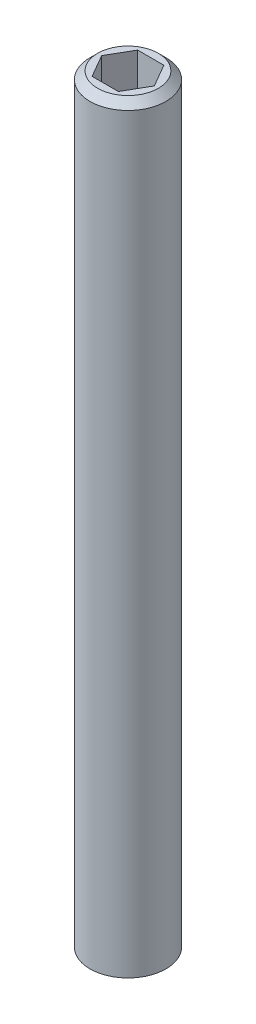
from build123d import *

# Parameters (mm, degrees)
SKETCH1_R           = 1.25
BOSS_EXTRUDE1_DEPTH = 25
CUT_EXTRUDE1_DEPTH  = 2
CHAMFER1_SIZE       = 0.25


with BuildPart() as part:
    # Sketch1 → Boss-Extrude1 (new body)
    with BuildSketch(Plane(origin=(0, 0, 0), x_dir=(1, 0, 0), z_dir=(0, 1, 0))):
        Circle(SKETCH1_R)
    extrude(amount=BOSS_EXTRUDE1_DEPTH)

    # Sketch2 → Cut-Extrude1 (cut)
    with BuildSketch(Plane(origin=(0, 25, 0), x_dir=(1, 0, 0), z_dir=(0, 1, 0))):
        Polygon((0.866025404, 0), (0.433012702, 0.75), (-0.433012702, 0.75), (-0.866025404, 0), (-0.433012702, -0.75), (0.433012702, -0.75), align=None)
    extrude(amount=-CUT_EXTRUDE1_DEPTH, mode=Mode.SUBTRACT)

    # Chamfer1
    chamfer1_edges = [part.edges().sort_by_distance(p)[0] for p in [
        (-1.25, 25, 0),
    ]]
    chamfer(chamfer1_edges, length=CHAMFER1_SIZE)


solid = part.part
